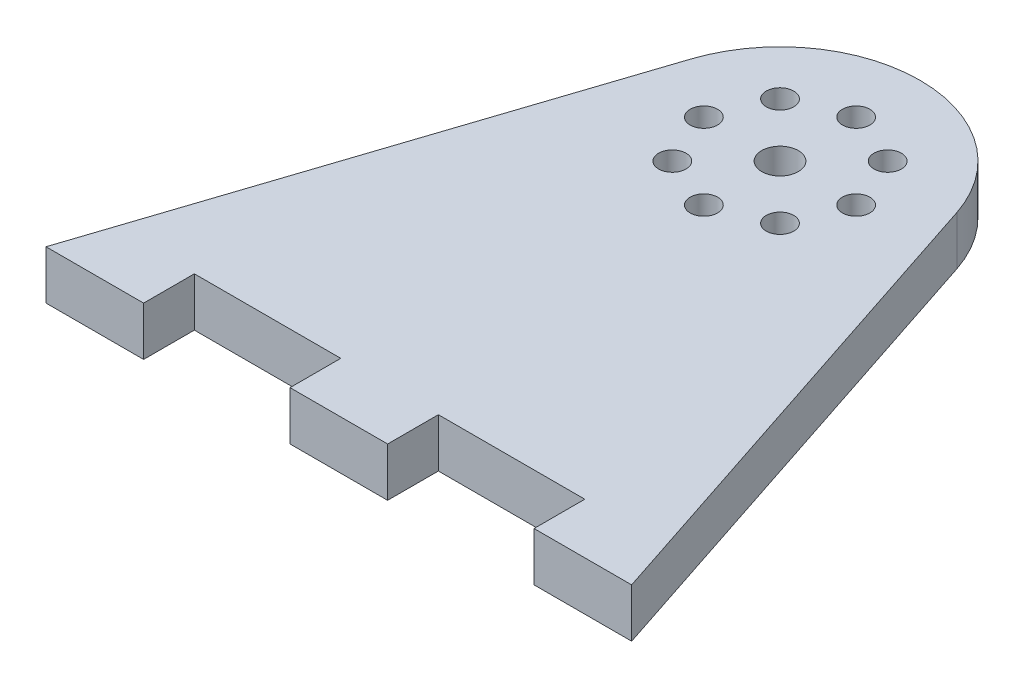
from build123d import *

# Parameters (mm, degrees)
SKETCH1_R           = 2.38125
SKETCH1_R_2         = 1.7859375
BOSS_EXTRUDE1_DEPTH = 6.35


with BuildPart() as part:
    # Sketch1 → Boss-Extrude1 (new body)
    with BuildSketch(Plane(origin=(0, 0, 0), x_dir=(1, 0, 0), z_dir=(0, 1, 0))):
        with BuildLine():
            Line((-38.1, -57.404), (-25.4, -57.404))
            Line((-25.4, -57.404), (-25.4, -50.8))
            Line((-25.4, -50.8), (-6.35, -50.8))
            Line((-6.35, -50.8), (-6.35, -57.404))
            Line((-6.35, -57.404), (6.35, -57.404))
            Line((6.35, -57.404), (6.35, -50.8))
            Line((6.35, -50.8), (25.4, -50.8))
            Line((25.4, -50.8), (25.4, -57.404))
            Line((25.4, -57.404), (38.1, -57.404))
            Line((38.1, -57.404), (17.302924237, 5.702287964))
            ThreePointArc((17.302924237, 5.702287964), (0, 18.218322512), (-17.302924237, 5.702287964))
            Line((-17.302924237, 5.702287964), (-38.1, -57.404))
        make_face()
        Circle(SKETCH1_R, mode=Mode.SUBTRACT)
        with Locations((-9.906, 0)):
            Circle(SKETCH1_R_2, mode=Mode.SUBTRACT)
        with Locations((-7.004599774, 7.004599774)):
            Circle(SKETCH1_R_2, mode=Mode.SUBTRACT)
        with Locations((0, 9.906)):
            Circle(SKETCH1_R_2, mode=Mode.SUBTRACT)
        with Locations((7.004599774, 7.004599774)):
            Circle(SKETCH1_R_2, mode=Mode.SUBTRACT)
        with Locations((9.906, 0)):
            Circle(SKETCH1_R_2, mode=Mode.SUBTRACT)
        with Locations((7.004599774, -7.004599774)):
            Circle(SKETCH1_R_2, mode=Mode.SUBTRACT)
        with Locations((0, -9.906)):
            Circle(SKETCH1_R_2, mode=Mode.SUBTRACT)
        with Locations((-7.004599774, -7.004599774)):
            Circle(SKETCH1_R_2, mode=Mode.SUBTRACT)
    extrude(amount=BOSS_EXTRUDE1_DEPTH)


solid = part.part
